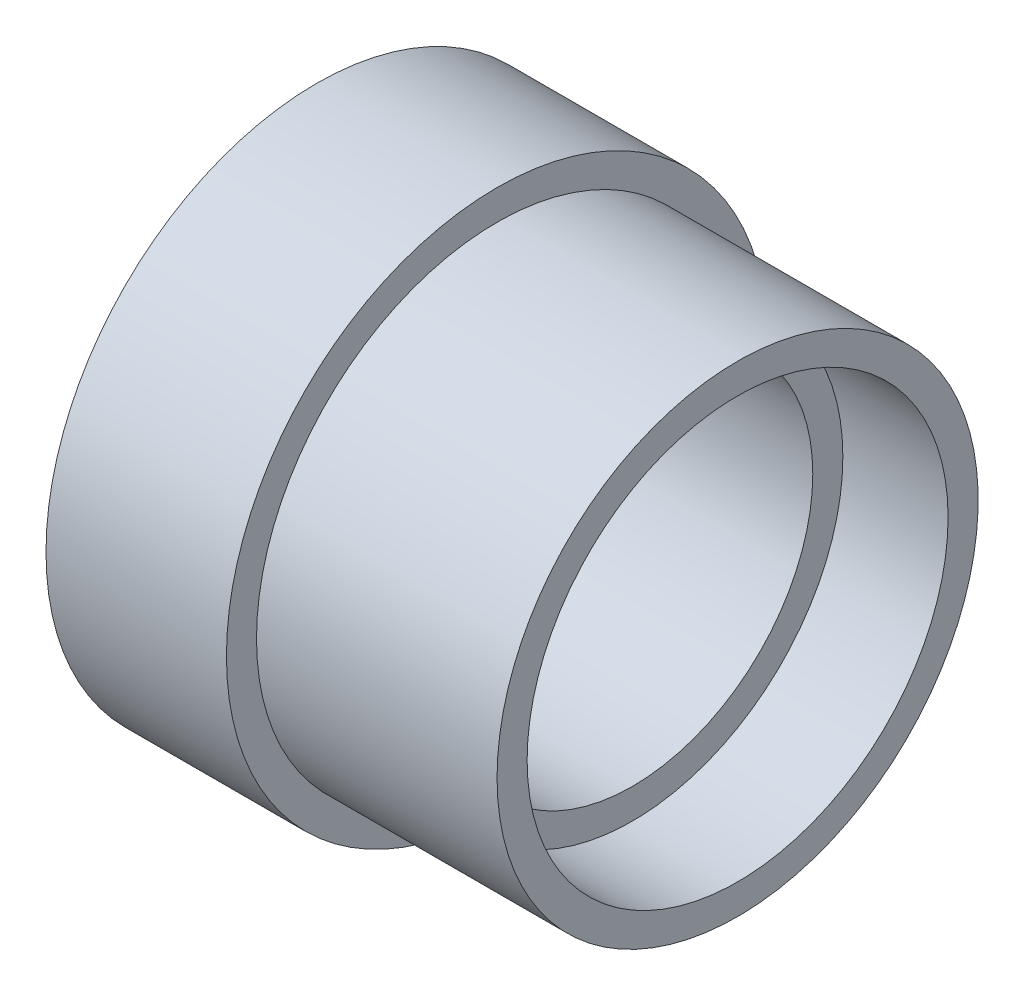
from build123d import *


with BuildPart() as part:
    # Эскиз1 → Повернуть1 (revolve)
    with BuildSketch(Plane.XY):
        Polygon((-3, -142), (-3, -140), (-19, -140), (-19, -138), (-31, -138), (-31, -142), (-24, -142), (-24, -144), (-10, -144), (-10, -142), align=None)
    revolve(axis=Axis((-1017, -156, 0), (1, 0, 0)))


solid = part.part
